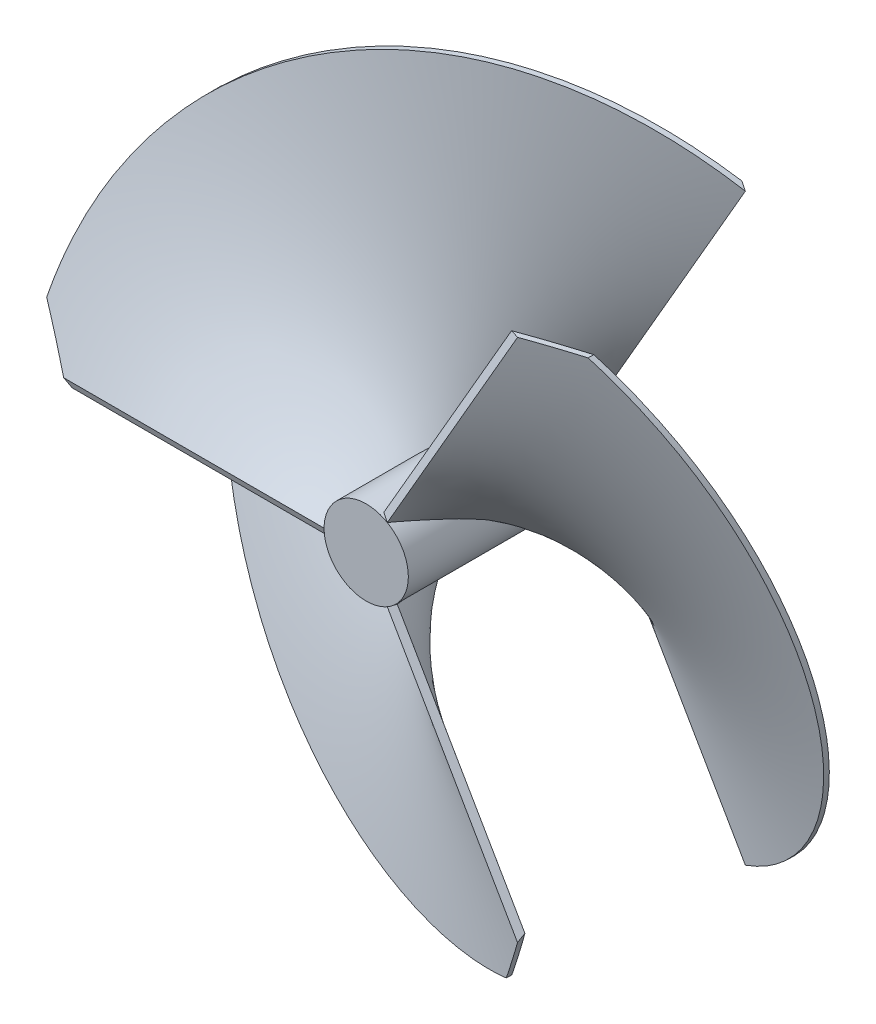
from build123d import *

# Parameters (mm, degrees)
SKETCH_1_R               = 10
EXTRUDE_1_DEPTH          = 50
SWEEP_1_PITCH            = 150
SWEEP_1_HEIGHT           = 49.995
SWEEP_1_RADIUS           = 10
SWEEP_1_START_ANGLE      = 180
SKETCH_3_W               = 70
SKETCH_3_H               = 2
SKETCH_5_OUTSIDE_W       = 155.499
SKETCH_5_OUTSIDE_H       = 123.937
CUT_EXTRUDE_2_DEPTH      = 40
CUT_EXTRUDE_2_DEPTH_BACK = 40
PATTERN_CIRCULAR_1_COUNT = 3


with BuildPart() as part:
    # Sketch 1 → Extrude 1 (new body)
    with BuildSketch(Plane.XY):
        Circle(SKETCH_1_R)
    extrude(amount=EXTRUDE_1_DEPTH)


with BuildPart() as body_2:
    # Sweep 1: sweep along a helix
    with BuildLine() as sweep_1_path:
        add(Helix(SWEEP_1_PITCH, SWEEP_1_HEIGHT, SWEEP_1_RADIUS, center=(0, 0, 0), direction=(0, 0, 1), mode=Mode.PRIVATE).rotate(Axis((0, 0, 0), (0, 0, 1)), SWEEP_1_START_ANGLE))
    # Sketch 3 → Sweep 1 (sweep)
    with BuildSketch(Plane(origin=(-10, 0, 0), x_dir=(1, 0, 0), z_dir=(0, -0.38635341, 0.922350824))):
        with Locations((-35, -1)):
            Rectangle(SKETCH_3_W, SKETCH_3_H)
    sweep(path=sweep_1_path.line, is_frenet=True)

    # Sketch 5 outside → Cut-Extrude 2 (cut, two sides)
    with BuildSketch(Plane.XY.offset(50)) as cut_extrude_2_sk:
        with Locations((-19.2085, -35.0105)):
            Rectangle(SKETCH_5_OUTSIDE_W, SKETCH_5_OUTSIDE_H)
        Polygon((-45, 0), (-60.931193012, -2.864376598), (-67.656326531, -6.387065584), (-71.819504424, -11.510976837), (-74.38146005, -18.876599263), (-77.26366013, -34.568577474), (-64.293759772, -73.958645228), (-32.005504299, -85.189342784), (9.202342258, -90.611356799), (28.737253909, -76.520600855), (38.028123343, -57.975584791), (32.408936411, -26.722588368), (7.464175573, 20.899227777), (-39.97540369, 12.369745989), align=None, mode=Mode.SUBTRACT)
    extrude(amount=CUT_EXTRUDE_2_DEPTH, mode=Mode.SUBTRACT)
    extrude(cut_extrude_2_sk.sketch, amount=-CUT_EXTRUDE_2_DEPTH_BACK, mode=Mode.SUBTRACT)


with BuildPart() as pattern_circular_1_1:
    # Pattern Circular 1: pattern copy
    add(body_2.part.rotate(Axis((0, 0, 50), (0, 0, -1)), 1 * 360 / PATTERN_CIRCULAR_1_COUNT))


with BuildPart() as pattern_circular_1_2:
    # Pattern Circular 1: pattern copy
    add(body_2.part.rotate(Axis((0, 0, 50), (0, 0, -1)), 2 * 360 / PATTERN_CIRCULAR_1_COUNT))


solid = Compound([part.part, body_2.part, pattern_circular_1_1.part, pattern_circular_1_2.part])
